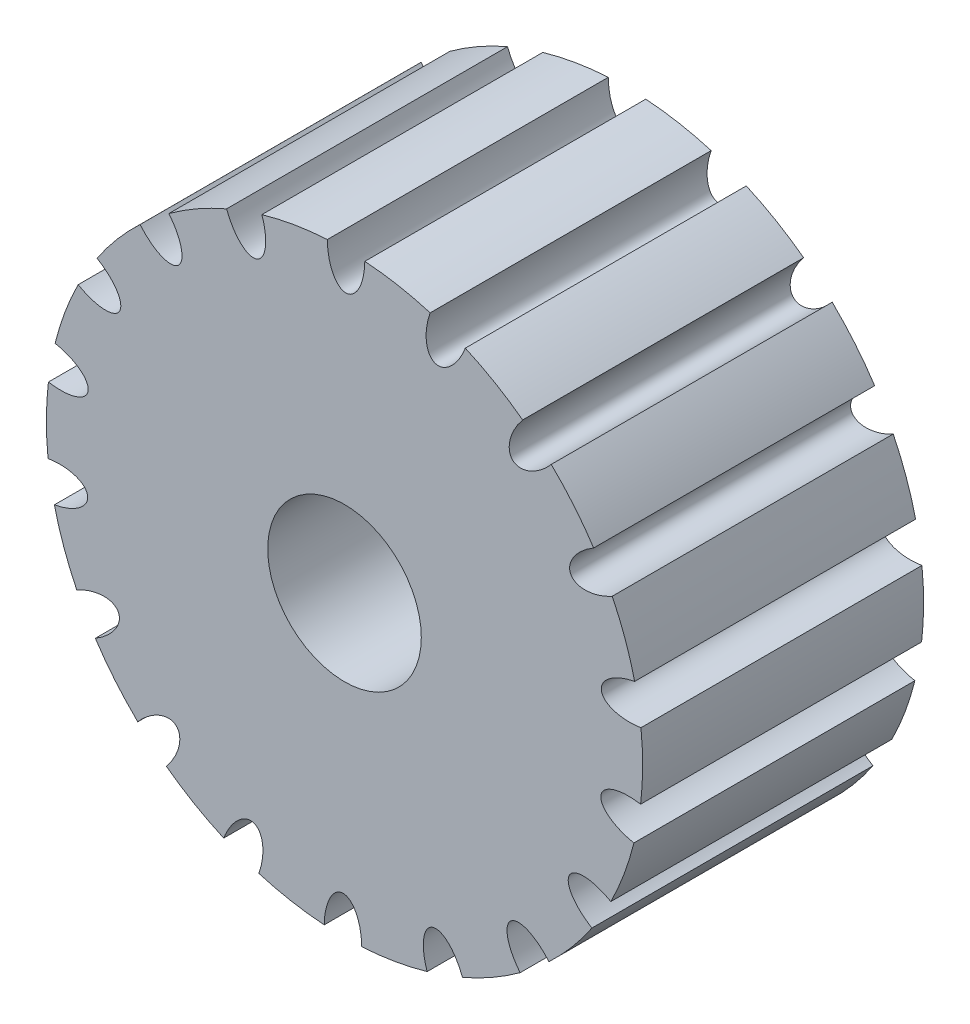
from build123d import *

# Parameters (mm, degrees)
SKETCH_1_R               = 15.91549431
EXTRUDE_1_DEPTH          = 15
SKETCH_2_R               = 4.1
CUT_EXTRUDE_5_DEPTH      = 15
SKETCH_5_RX              = 2
SKETCH_5_RY              = 1
CUT_EXTRUDE_6_DEPTH      = 15
PATTERN_CIRCULAR_2_COUNT = 18


with BuildPart() as part:
    # Эскиз1 → Бобышка-Вытянуть1 (new body)
    with BuildSketch(Plane.XY):
        Circle(SKETCH_1_R)
    extrude(amount=EXTRUDE_1_DEPTH)

    # Эскиз2 → Вырез-Вытянуть5 (cut)
    with BuildSketch(Plane.XY.offset(15)):
        Circle(SKETCH_2_R)
    extrude(amount=-CUT_EXTRUDE_5_DEPTH, mode=Mode.SUBTRACT)

    # Эскиз5 → Вырез-Вытянуть6 (cut)
    with BuildSketch(Plane.XY.offset(15)):
        with Locations(Location((0.082802385, 15.915278914), (0, 0, 89.70191007))):
            Ellipse(SKETCH_5_RX, SKETCH_5_RY)
    cut_extrude_6 = extrude(amount=-CUT_EXTRUDE_6_DEPTH, mode=Mode.SUBTRACT)

    # Круговой массив2: Вырез-Вытянуть6 ×18 about axis
    pattern_circular_2_axis = Axis((0, 0, 0), (0, 0, 1))
    for i in range(1, PATTERN_CIRCULAR_2_COUNT):
        add(cut_extrude_6.rotate(pattern_circular_2_axis, i * 360 / PATTERN_CIRCULAR_2_COUNT), mode=Mode.SUBTRACT)


solid = part.part
